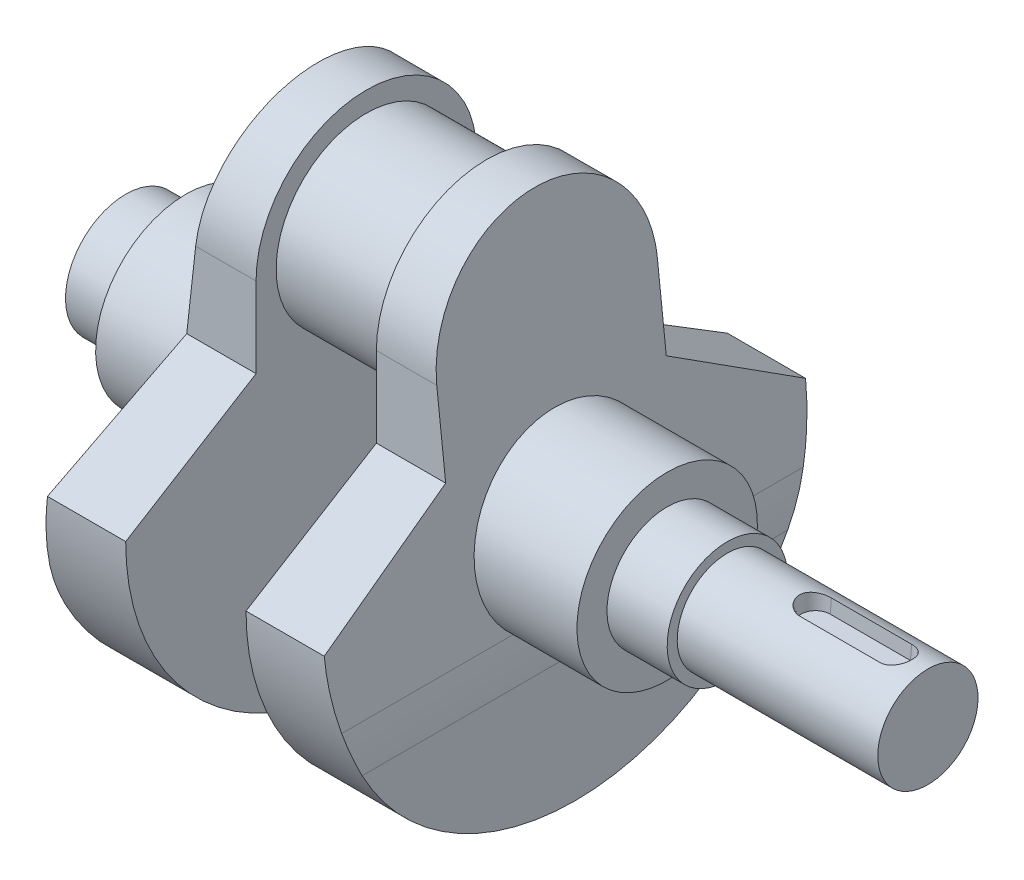
from build123d import *

# Parameters (mm, degrees)
SKETCH1_R               = 22.5
BOSS_EXTRUDE1_DEPTH     = 15
BOSS_EXTRUDE2_DEPTH     = 22
CUT_EXTRUDE1_DEPTH      = 61
CUT_EXTRUDE1_DEPTH_BACK = 61
FILLET1_R               = 100
CUT_EXTRUDE2_START      = -27.5
CUT_EXTRUDE2_DEPTH      = 4
CUT_EXTRUDE2_TAPER      = 5
CUT_EXTRUDE3_DEPTH      = 61.0000001
CUT_EXTRUDE3_DEPTH_BACK = 61.0000001


with BuildPart() as part:
    # Sketch1 → Boss-Extrude1 (new body)
    with BuildSketch(Plane(origin=(0, 0, 0), x_dir=(0, 0, -1), z_dir=(1, 0, 0))):
        Circle(SKETCH1_R)
    extrude(amount=BOSS_EXTRUDE1_DEPTH)

    # Sketch2 → Boss-Extrude2 (add)
    with BuildSketch(Plane(origin=(15, 0, 0), x_dir=(0, 0, -1), z_dir=(1, 0, 0))):
        with BuildLine():
            Line((-27.5, 0), (-27.5, -20))
            Line((-27.5, -20), (-60, -40))
            ThreePointArc((-60, -40), (0, -100), (60, -40))
            Line((60, -40), (27.5, -20))
            Line((27.5, -20), (27.5, 0))
            ThreePointArc((27.5, 0), (0, 27.5), (-27.5, 0))
        make_face()
    extrude(amount=BOSS_EXTRUDE2_DEPTH)

    # Sketch3 → Cut-Extrude1 (cut, two sides)
    with BuildSketch(Plane.XY) as cut_extrude1_sk:
        Polygon((27, 27.5), (37, 27.5), (37, -62.5), align=None)
    extrude(amount=CUT_EXTRUDE1_DEPTH, mode=Mode.SUBTRACT)
    extrude(cut_extrude1_sk.sketch, amount=-CUT_EXTRUDE1_DEPTH_BACK, mode=Mode.SUBTRACT)

    # Fillet1
    fillet1_edges = [part.edges().sort_by_distance(p)[0] for p in [
        (37, -62.5, 0),
    ]]
    fillet(fillet1_edges, radius=FILLET1_R)

    # Sketch4 → Revolve1 (revolve)
    with BuildSketch(Plane.XY):
        Polygon((25.790103906, -17.5), (60, -17.5), (60, -25), (75, -25), (75, -27.5), (125, -27.5), (125, -40), (25.790103906, -40), align=None)
    revolve(axis=Axis((125, -40, 0), (-1, 0, 0)))

    # Sketch5 → Cut-Extrude2 (cut)
    with BuildSketch(Plane(origin=(0, 0, 0), x_dir=(1, 0, 0), z_dir=(0, 1, 0)).offset(CUT_EXTRUDE2_START)):
        with BuildLine():
            ThreePointArc((97, 4), (93, 0), (97, -4))
            Line((97, -4), (117, -4))
            ThreePointArc((117, -4), (121, 0), (117, 4))
            Line((117, 4), (97, 4))
        make_face()
    extrude(amount=-CUT_EXTRUDE2_DEPTH, taper=CUT_EXTRUDE2_TAPER, mode=Mode.SUBTRACT)

    # Mirror1: part across plane


with BuildPart() as part_1:
    add(part.part)
    add(part.part.mirror(Plane(origin=(0, 0, 0), x_dir=(0, 0, 1), z_dir=(1, 0, 0))))

    # Sketch6 → Cut-Extrude3 (cut, two sides)
    with BuildSketch(Plane.XY) as cut_extrude3_sk:
        Polygon((-75, -520.584014882), (-75, -67.635702331), (-75, -7.558349371), (-75, 445.38996318), (-980.896625102, 445.38996318), (-980.896625102, -520.584014882), align=None)
    extrude(amount=CUT_EXTRUDE3_DEPTH, mode=Mode.SUBTRACT)
    extrude(cut_extrude3_sk.sketch, amount=-CUT_EXTRUDE3_DEPTH_BACK, mode=Mode.SUBTRACT)


solid = part_1.part
